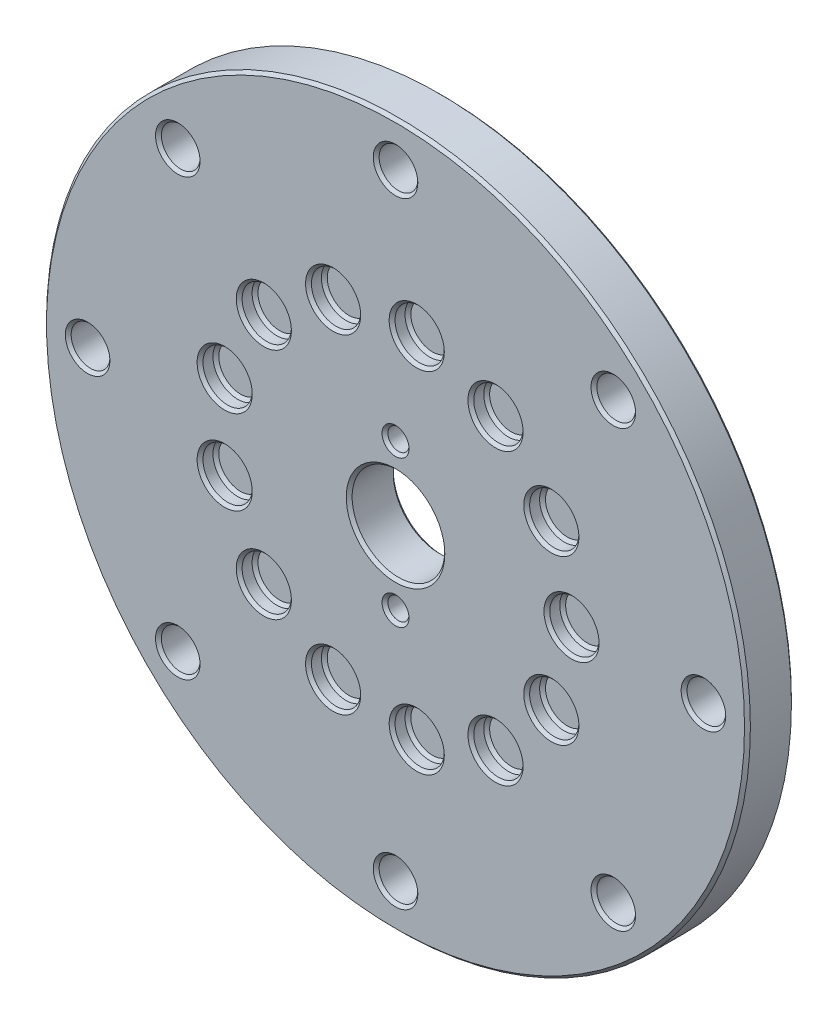
from build123d import *

# Parameters (mm, degrees)
SKETCH1_R            = 60
SKETCH1_R_2          = 7.9
BOSS_EXTRUDE1_DEPTH  = 8
M6_CLEARANCE_HOLE1_D = 6.6
M3_CLEARANCE_HOLE1_D = 3.6
SKETCH8_R            = 4.2
CUT_EXTRUDE1_DEPTH   = 2.7
CHAMFER1_SIZE        = 0.5


with BuildPart() as part:
    # Sketch1 → Boss-Extrude1 (new body)
    with BuildSketch(Plane.XY):
        Circle(SKETCH1_R)
        Circle(SKETCH1_R_2, mode=Mode.SUBTRACT)
    extrude(amount=BOSS_EXTRUDE1_DEPTH)

    # M6 Clearance Hole1 (through all)
    with Locations(Plane.XY.offset(8)):
        with Locations((-37.123106012, 37.123106012), (0, 52.5), (37.123106012, 37.123106012), (52.5, 0), (37.123106012, -37.123106012), (0, -52.5), (-37.123106012, -37.123106012), (-52.5, 0)):
            Hole(M6_CLEARANCE_HOLE1_D / 2)

    # M3 Clearance Hole1 (through all)
    with Locations(Plane.XY.offset(8)):
        with Locations((0, 12.5), (0, -12.5), (0, 0)):
            Hole(M3_CLEARANCE_HOLE1_D / 2)

    # Sketch8 → Cut-Extrude1 (cut)
    with BuildSketch(Plane.XY.offset(8)):
        with Locations((30, 0)):
            Circle(SKETCH8_R)
        with Locations((26.56368077, -13.941695161)):
            Circle(SKETCH8_R)
        with Locations((17.041942402, -24.689515977)):
            Circle(SKETCH8_R)
        with Locations((3.616100408, -29.781266223)):
            Circle(SKETCH8_R)
        with Locations((-10.638146611, -28.050487281)):
            Circle(SKETCH8_R)
        with Locations((-22.455322445, -19.893679747)):
            Circle(SKETCH8_R)
        with Locations((-29.128254523, -7.179469929)):
            Circle(SKETCH8_R)
        with Locations((-29.128254523, 7.179469929)):
            Circle(SKETCH8_R)
        with Locations((-22.455322445, 19.893679747)):
            Circle(SKETCH8_R)
        with Locations((-10.638146611, 28.050487281)):
            Circle(SKETCH8_R)
        with Locations((3.616100408, 29.781266223)):
            Circle(SKETCH8_R)
        with Locations((17.041942402, 24.689515977)):
            Circle(SKETCH8_R)
        with Locations((26.56368077, 13.941695161)):
            Circle(SKETCH8_R)
    extrude(amount=-CUT_EXTRUDE1_DEPTH, mode=Mode.SUBTRACT)

    # Chamfer1
    chamfer1_edges = [part.edges().sort_by_distance(p)[0] for p in [
        (25.8, 0, 5.3),
        (25.8, 0, 8),
        (-33.823106012, 37.123106012, 8),
        (-33.823106012, 37.123106012, 0),
        (-60, 0, 0),
        (-49.2, 0, 8),
        (-49.2, 0, 0),
        (-33.823106012, -37.123106012, 8),
        (-33.823106012, -37.123106012, 0),
        (3.3, -52.5, 8),
        (3.3, -52.5, 0),
        (40.423106012, -37.123106012, 8),
        (40.423106012, -37.123106012, 0),
        (55.8, 0, 8),
        (55.8, 0, 0),
        (40.423106012, 37.123106012, 8),
        (40.423106012, 37.123106012, 0),
        (-60, 0, 8),
        (-7.9, 0, 0),
        (3.3, 52.5, 8),
        (3.3, 52.5, 0),
        (-7.9, 0, 8),
        (1.8, -12.5, 8),
        (1.8, -12.5, 0),
        (1.8, 12.5, 8),
        (1.8, 12.5, 0),
        (22.36368077, -13.941695161, 5.3),
        (22.36368077, -13.941695161, 8),
        (12.841942402, -24.689515977, 5.3),
        (12.841942402, -24.689515977, 8),
        (-0.583899592, -29.781266223, 5.3),
        (-0.583899592, -29.781266223, 8),
        (-14.838146611, -28.050487281, 5.3),
        (-14.838146611, -28.050487281, 8),
        (-26.655322445, -19.893679747, 5.3),
        (-26.655322445, -19.893679747, 8),
        (-33.328254523, -7.179469929, 5.3),
        (-33.328254523, -7.179469929, 8),
        (-33.328254523, 7.179469929, 5.3),
        (-33.328254523, 7.179469929, 8),
        (-26.655322445, 19.893679747, 5.3),
        (-26.655322445, 19.893679747, 8),
        (-14.838146611, 28.050487281, 5.3),
        (-14.838146611, 28.050487281, 8),
        (-0.583899592, 29.781266223, 5.3),
        (-0.583899592, 29.781266223, 8),
        (12.841942402, 24.689515977, 5.3),
        (12.841942402, 24.689515977, 8),
        (22.36368077, 13.941695161, 5.3),
        (22.36368077, 13.941695161, 8),
    ]]
    chamfer(chamfer1_edges, length=CHAMFER1_SIZE)


solid = part.part
